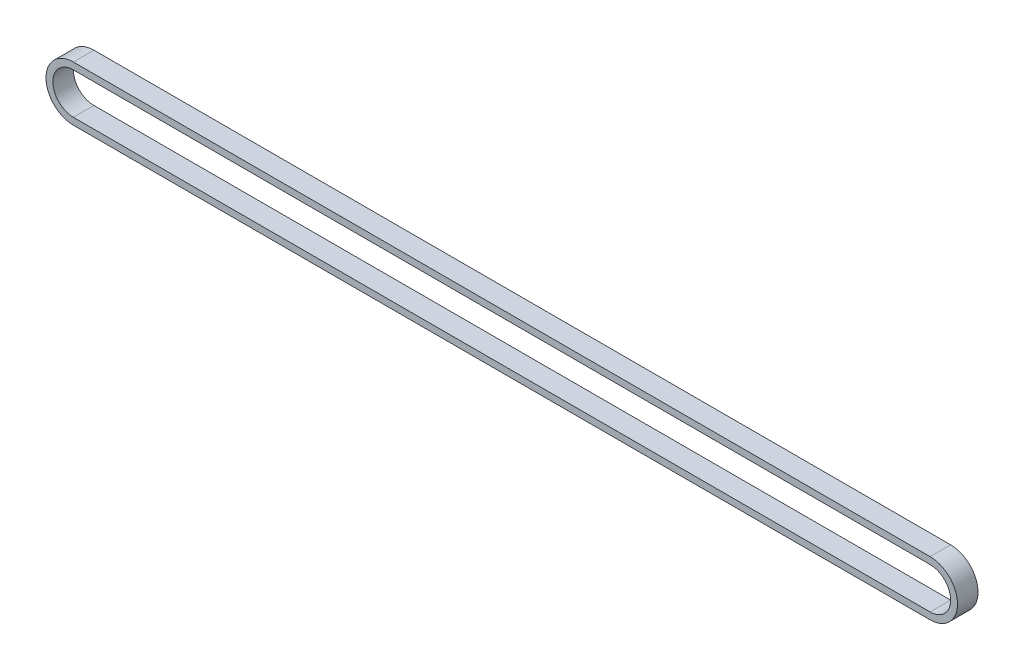
from build123d import *

# Parameters (mm, degrees)
RESSALTO_EXTRUS_O1_DEPTH = 6


with BuildPart() as part:
    # Esboço1 → Ressalto-extrusão1 (new body)
    with BuildSketch(Plane.XY):
        with BuildLine():
            Line((-125.25, 8), (125.25, 8))
            ThreePointArc((125.25, 8), (133.25, 0), (125.25, -8))
            Line((125.25, -8), (-125.25, -8))
            ThreePointArc((-125.25, -8), (-133.25, 0), (-125.25, 8))
        make_face()
        with BuildLine():
            Line((-125.25, 6), (125.25, 6))
            ThreePointArc((125.25, 6), (131.25, 0), (125.25, -6))
            Line((125.25, -6), (-125.25, -6))
            ThreePointArc((-125.25, -6), (-131.25, 0), (-125.25, 6))
        make_face(mode=Mode.SUBTRACT)
    extrude(amount=RESSALTO_EXTRUS_O1_DEPTH)


solid = part.part
